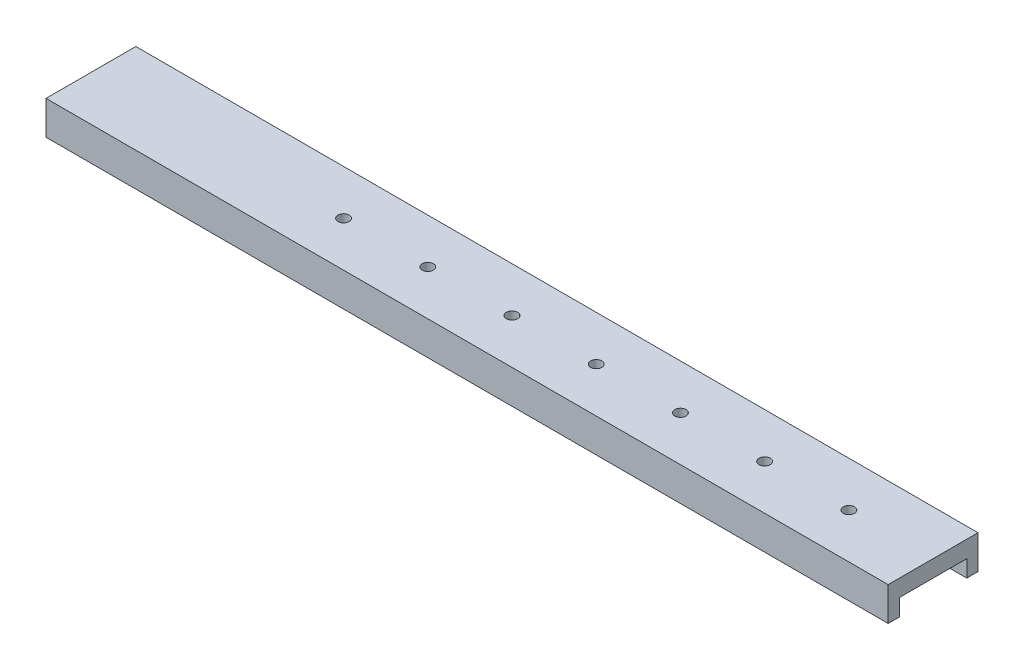
from build123d import *

# Parameters (mm, degrees)
IZIM2_W                     = 750
IZIM2_H                     = 80
IZIM2_R                     = 5
Y_KSEKLIK_EKSTR_ZYON1_DEPTH = 30
IZIM3_W                     = 60
IZIM3_H                     = 15
KES_EKSTR_ZYON1_DEPTH       = 600


with BuildPart() as part:
    # Çizim2 → Yükseklik-Ekstrüzyon1 (new body)
    with BuildSketch(Plane(origin=(0, 0, 0), x_dir=(1, 0, 0), z_dir=(0, 1, 0))):
        Rectangle(IZIM2_W, IZIM2_H)
        with Locations((300, 0)):
            Circle(IZIM2_R, mode=Mode.SUBTRACT)
        with Locations((225, 0)):
            Circle(IZIM2_R, mode=Mode.SUBTRACT)
        with Locations((150, 0)):
            Circle(IZIM2_R, mode=Mode.SUBTRACT)
        with Locations((75, 0)):
            Circle(IZIM2_R, mode=Mode.SUBTRACT)
        Circle(IZIM2_R, mode=Mode.SUBTRACT)
        with Locations((-75, 0)):
            Circle(IZIM2_R, mode=Mode.SUBTRACT)
        with Locations((-150, 0)):
            Circle(IZIM2_R, mode=Mode.SUBTRACT)
    extrude(amount=-Y_KSEKLIK_EKSTR_ZYON1_DEPTH)

    # Çizim3 → Kes-Ekstrüzyon1 (cut)
    with BuildSketch(Plane(origin=(375, 0, 0), x_dir=(0, 0, -1), z_dir=(1, 0, 0))):
        with Locations((0, -22.5)):
            Rectangle(IZIM3_W, IZIM3_H)
    extrude(amount=-KES_EKSTR_ZYON1_DEPTH, mode=Mode.SUBTRACT)


solid = part.part
